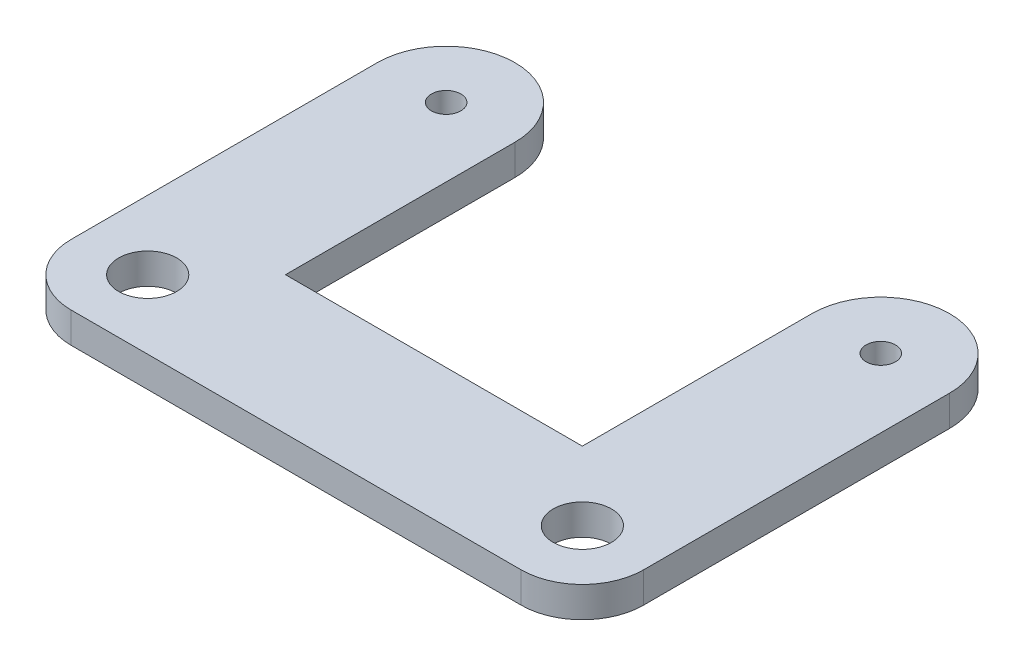
from build123d import *

# Parameters (mm, degrees)
SKETCH1_R           = 4.75
SKETCH1_R_2         = 11.25
SKETCH1_R_3         = 2.4
BOSS_EXTRUDE1_DEPTH = 5
FILLET1_R           = 10


with BuildPart() as part:
    # Sketch1 → Boss-Extrude1 (new body)
    with BuildSketch(Plane(origin=(0, 0, 0), x_dir=(1, 0, 0), z_dir=(0, 1, 0))):
        with BuildLine():
            Line((-24.25, -37.5), (-24.25, 0))
            ThreePointArc((-24.25, 0), (-35.5, -11.25), (-46.75, 0))
            Line((-46.75, 0), (-46.75, -60))
            Line((-46.75, -60), (46.75, -60))
            Line((46.75, -60), (46.75, 0))
            ThreePointArc((46.75, 0), (35.5, -11.25), (24.25, 0))
            Line((24.25, 0), (24.25, -37.5))
            Line((24.25, -37.5), (-24.25, -37.5))
        make_face()
        with Locations((-35.5, -48.75)):
            Circle(SKETCH1_R, mode=Mode.SUBTRACT)
        with Locations((35.5, -48.75)):
            Circle(SKETCH1_R, mode=Mode.SUBTRACT)
        with Locations((-35.5, 0)):
            Circle(SKETCH1_R_2)
        with Locations((-35.5, 0)):
            Circle(SKETCH1_R_3, mode=Mode.SUBTRACT)
        with Locations((35.5, 0)):
            Circle(SKETCH1_R_2)
        with Locations((35.5, 0)):
            Circle(SKETCH1_R_3, mode=Mode.SUBTRACT)
    extrude(amount=BOSS_EXTRUDE1_DEPTH)

    # Fillet1
    fillet1_edges = [part.edges().sort_by_distance(p)[0] for p in [
        (46.75, 2.5, 60),
        (-46.75, 2.5, 60),
    ]]
    fillet(fillet1_edges, radius=FILLET1_R)


solid = part.part
